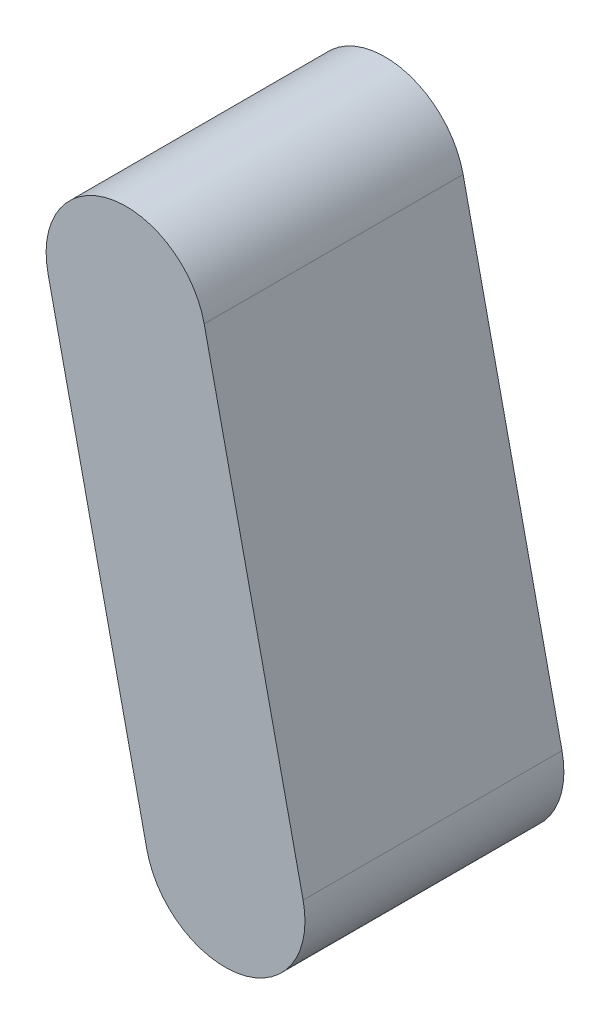
from build123d import *

# Parameters (mm, degrees)
BOSS_EXTRUDE1_DEPTH = 114.3


with BuildPart() as part:
    # Sketch1 → Boss-Extrude1 (new body)
    with BuildSketch(Plane.XY):
        with BuildLine():
            Line((-2036.569847385, 382.11010998), (-1992.90914464, 183.656127818))
            ThreePointArc((-1992.90914464, 183.656127818), (-1950.841718137, 156.76079552), (-1923.946385838, 198.828222023))
            Line((-1923.946385838, 198.828222023), (-1967.607088584, 397.282204184))
            ThreePointArc((-1967.607088584, 397.282204184), (-2009.674515087, 424.177536483), (-2036.569847385, 382.11010998))
        make_face()
    extrude(amount=-BOSS_EXTRUDE1_DEPTH)


solid = part.part
